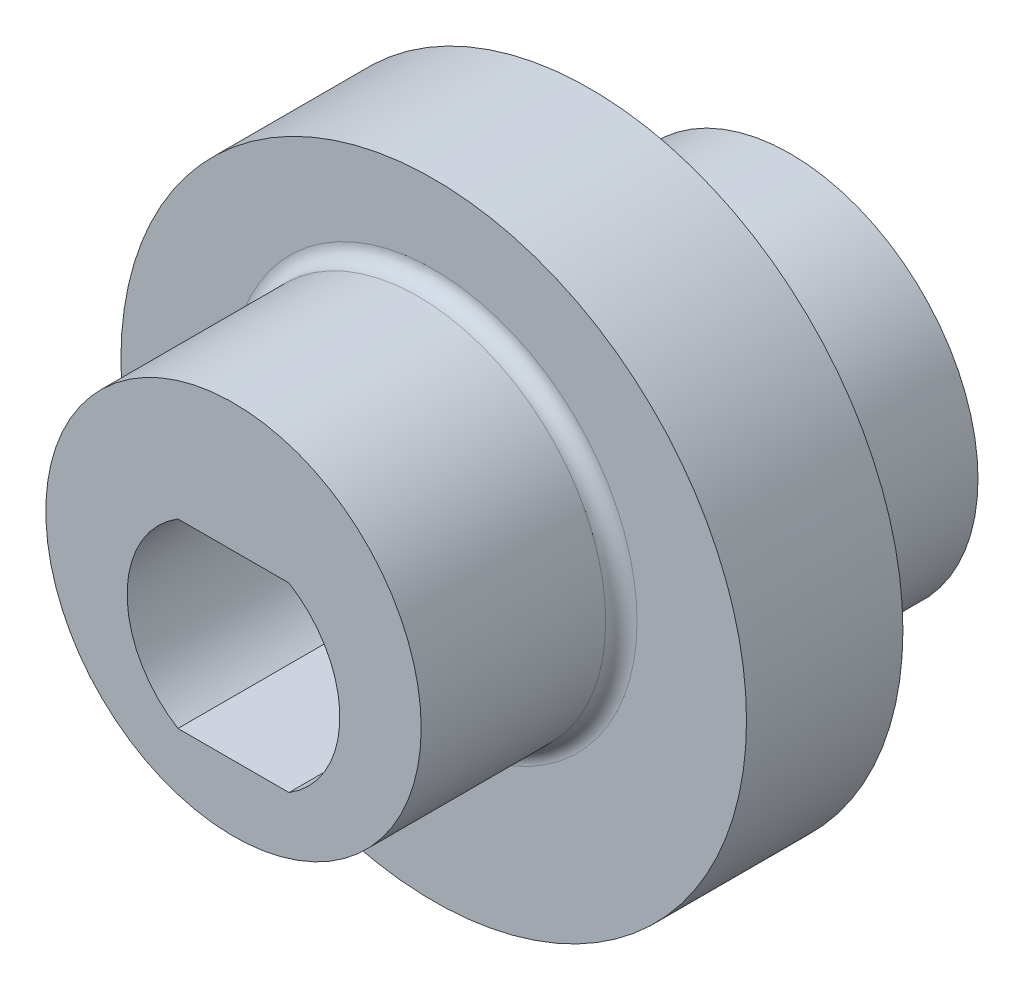
from build123d import *

# Parameters (mm, degrees)
SKETCH6_R               = 10
BOSS_EXTRUDE4_DEPTH     = 2.5
SKETCH7_R               = 6
BOSS_EXTRUDE5_DEPTH     = 6.4
SKETCH8_R               = 6
BOSS_EXTRUDE6_DEPTH     = 6.4
CUT_EXTRUDE1_DEPTH      = 7.4
CUT_EXTRUDE1_DEPTH_BACK = 12.4
FILLET1_R               = 0.5


with BuildPart() as part:
    # Sketch6 → Boss-Extrude4 (new body, symmetric)
    with BuildSketch(Plane.XY):
        Circle(SKETCH6_R)
    extrude(amount=BOSS_EXTRUDE4_DEPTH, both=True)

    # Sketch7 → Boss-Extrude5 (add)
    with BuildSketch(Plane.XY.offset(2.5)):
        with Locations((0, 1)):
            Circle(SKETCH7_R)
    extrude(amount=BOSS_EXTRUDE5_DEPTH)

    # Sketch8 → Boss-Extrude6 (add)
    with BuildSketch(Plane(origin=(0, 0, -2.5), x_dir=(-1, 0, 0), z_dir=(0, 0, -1))):
        with Locations((0, -1)):
            Circle(SKETCH8_R)
    extrude(amount=BOSS_EXTRUDE6_DEPTH)

    # Sketch11 → Cut-Extrude1 (cut, two sides)
    with BuildSketch(Plane.XY.offset(2.5)) as cut_extrude1_sk:
        with BuildLine():
            Line((-1.774823935, -2.9), (1.774823935, -2.9))
            ThreePointArc((1.774823935, -2.9), (3.4, 0), (1.774823935, 2.9))
            Line((1.774823935, 2.9), (-1.774823935, 2.9))
            ThreePointArc((-1.774823935, 2.9), (-3.4, 0), (-1.774823935, -2.9))
        make_face()
    extrude(amount=CUT_EXTRUDE1_DEPTH, mode=Mode.SUBTRACT)
    extrude(cut_extrude1_sk.sketch, amount=-CUT_EXTRUDE1_DEPTH_BACK, mode=Mode.SUBTRACT)

    # Fillet1
    fillet1_edges = [part.edges().sort_by_distance(p)[0] for p in [
        (6, -1, -2.5),
        (-6, 1, 2.5),
    ]]
    fillet(fillet1_edges, radius=FILLET1_R)


solid = part.part
